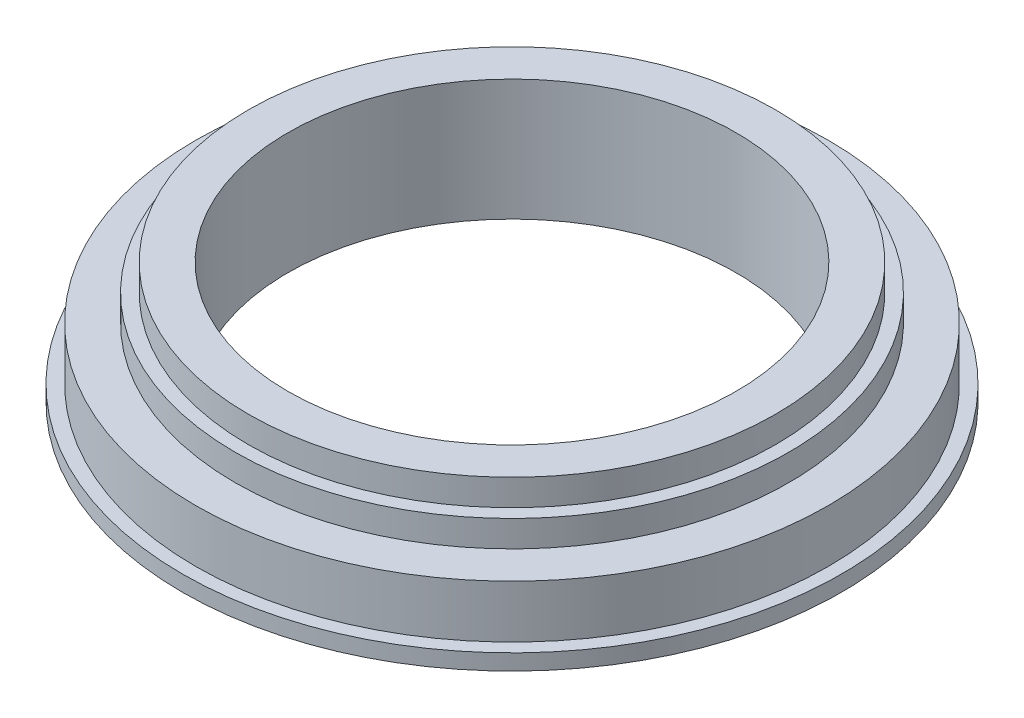
from build123d import *

# Parameters (mm, degrees)
SKETCH1_R           = 62.5
BOSS_EXTRUDE1_DEPTH = 3
SKETCH2_R           = 60
SKETCH2_R_2         = 52.5
BOSS_EXTRUDE2_DEPTH = 10
SKETCH3_R           = 52.5
SKETCH3_R_2         = 50
BOSS_EXTRUDE3_DEPTH = 15
SKETCH4_R           = 50
SKETCH4_R_2         = 42.5
BOSS_EXTRUDE4_DEPTH = 20
SKETCH5_R           = 42.5
CUT_EXTRUDE1_DEPTH  = 4


with BuildPart() as part:
    # Sketch1 → Boss-Extrude1 (new body)
    with BuildSketch(Plane(origin=(0, 0, 0), x_dir=(1, 0, 0), z_dir=(0, 1, 0))):
        Circle(SKETCH1_R)
    extrude(amount=BOSS_EXTRUDE1_DEPTH)

    # Sketch2 → Boss-Extrude2 (add)
    with BuildSketch(Plane(origin=(0, 3, 0), x_dir=(1, 0, 0), z_dir=(0, 1, 0))):
        Circle(SKETCH2_R)
        Circle(SKETCH2_R_2, mode=Mode.SUBTRACT)
    extrude(amount=BOSS_EXTRUDE2_DEPTH)

    # Sketch3 → Boss-Extrude3 (add)
    with BuildSketch(Plane(origin=(0, 3, 0), x_dir=(1, 0, 0), z_dir=(0, 1, 0))):
        Circle(SKETCH3_R)
        Circle(SKETCH3_R_2, mode=Mode.SUBTRACT)
    extrude(amount=BOSS_EXTRUDE3_DEPTH)

    # Sketch4 → Boss-Extrude4 (add)
    with BuildSketch(Plane(origin=(0, 3, 0), x_dir=(1, 0, 0), z_dir=(0, 1, 0))):
        Circle(SKETCH4_R)
        Circle(SKETCH4_R_2, mode=Mode.SUBTRACT)
    extrude(amount=BOSS_EXTRUDE4_DEPTH)

    # Sketch5 → Cut-Extrude1 (cut, through all)
    with BuildSketch(Plane(origin=(0, 3, 0), x_dir=(1, 0, 0), z_dir=(0, 1, 0))):
        Circle(SKETCH5_R)
    extrude(amount=-CUT_EXTRUDE1_DEPTH, mode=Mode.SUBTRACT)


solid = part.part
